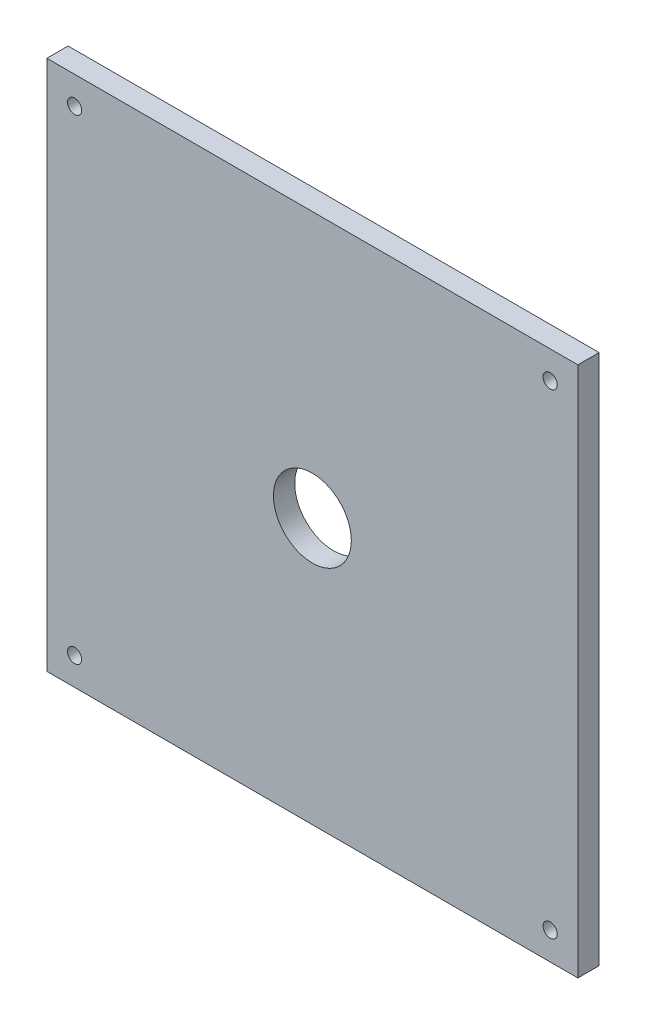
from build123d import *

# Parameters (mm, degrees)
SKETCH1_W           = 150
SKETCH1_H           = 150
SKETCH1_R           = 11
BOSS_EXTRUDE1_DEPTH = 6
SKETCH2_R           = 2
CUT_EXTRUDE1_DEPTH  = 10


with BuildPart() as part:
    # Sketch1 → Boss-Extrude1 (new body)
    with BuildSketch(Plane.XY):
        Rectangle(SKETCH1_W, SKETCH1_H)
        Circle(SKETCH1_R, mode=Mode.SUBTRACT)
    extrude(amount=BOSS_EXTRUDE1_DEPTH)

    # Sketch2 → Cut-Extrude1 (cut)
    with BuildSketch(Plane.XY.offset(6)):
        with Locations((67.175144213, 67.175144213)):
            Circle(SKETCH2_R)
        with Locations((67.175144213, -67.175144213)):
            Circle(SKETCH2_R)
        with Locations((-67.175144213, -67.175144213)):
            Circle(SKETCH2_R)
        with Locations((-67.175144213, 67.175144213)):
            Circle(SKETCH2_R)
    extrude(amount=-CUT_EXTRUDE1_DEPTH, mode=Mode.SUBTRACT)


solid = part.part
